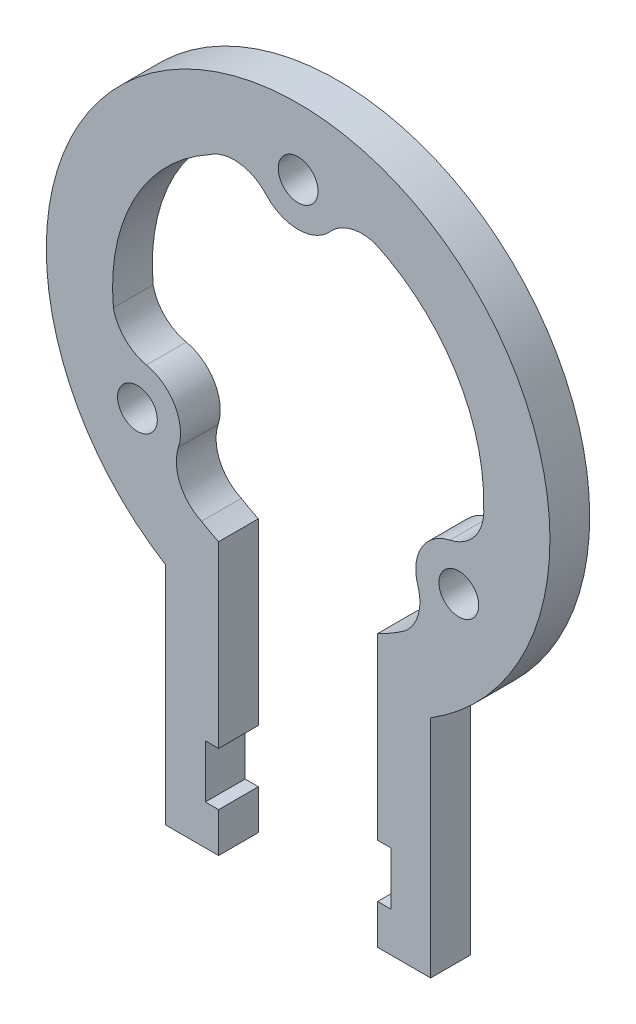
from build123d import *

# Parameters (mm, degrees)
ESQUISSE1_R        = 1.5
BOSS_EXTRU_2_DEPTH = 3


with BuildPart() as part:
    # Esquisse1 → Boss.-Extru.2 (new body)
    with BuildSketch(Plane.XY):
        with BuildLine():
            Line((-6, -33.155494421), (-6, -30.155494421))
            Line((-6, -30.155494421), (-7, -30.155494421))
            Line((-7, -30.155494421), (-7, -26.155494421))
            Line((-7, -26.155494421), (-6, -26.155494421))
            Line((-6, -26.155494421), (-6, -12.649110641))
            ThreePointArc((-6, -12.649110641), (-6.653410863, -12.317959405), (-7.288606081, -11.953084179))
            ThreePointArc((-7.288606081, -11.953084179), (-8.912631465, -10.307392628), (-9.031496673, -7.998360322))
            ThreePointArc((-9.031496673, -7.998360322), (-9.309773091, -5.375), (-11.442531564, -3.822325392))
            ThreePointArc((-11.442531564, -3.822325392), (-13.054716827, -2.946828253), (-13.935938611, -1.337764944))
            ThreePointArc((-13.935938611, -1.337764944), (-12.367555464, 6.560760004), (-6.707371512, 12.288660114))
            ThreePointArc((-6.707371512, 12.288660114), (-4.47014813, 12.872261577), (-2.411034891, 11.820685714))
            ThreePointArc((-2.411034891, 11.820685714), (0, 10.75), (2.411034891, 11.820685714))
            ThreePointArc((2.411034891, 11.820685714), (3.975330286, 12.779130538), (5.80943088, 12.737759334))
            ThreePointArc((5.80943088, 12.737759334), (11.865562564, 7.430237213), (13.995977593, -0.335575935))
            ThreePointArc((13.995977593, -0.335575935), (13.382779595, -2.564868949), (11.442531564, -3.822325392))
            ThreePointArc((11.442531564, -3.822325392), (9.309773091, -5.375), (9.031496673, -7.998360322))
            ThreePointArc((9.031496673, -7.998360322), (9.079386541, -9.832302285), (8.126507731, -11.399994391))
            ThreePointArc((8.126507731, -11.399994391), (7.090812931, -12.071469338), (6, -12.649110641))
            Line((6, -12.649110641), (6, -26.155494421))
            Line((6, -26.155494421), (7, -26.155494421))
            Line((7, -26.155494421), (7, -30.155494421))
            Line((7, -30.155494421), (6, -30.155494421))
            Line((6, -30.155494421), (6, -33.155494421))
            Line((6, -33.155494421), (10, -33.155494421))
            Line((10, -33.155494421), (10, -16.155494421))
            ThreePointArc((10, -16.155494421), (0, 19), (-10, -16.155494421))
            Line((-10, -16.155494421), (-10, -33.155494421))
            Line((-10, -33.155494421), (-6, -33.155494421))
        make_face()
        with Locations((0, 14)):
            Circle(ESQUISSE1_R, mode=Mode.SUBTRACT)
        with Locations((12.124355653, -7)):
            Circle(ESQUISSE1_R, mode=Mode.SUBTRACT)
        with Locations((-12.124355653, -7)):
            Circle(ESQUISSE1_R, mode=Mode.SUBTRACT)
    extrude(amount=BOSS_EXTRU_2_DEPTH)


solid = part.part
